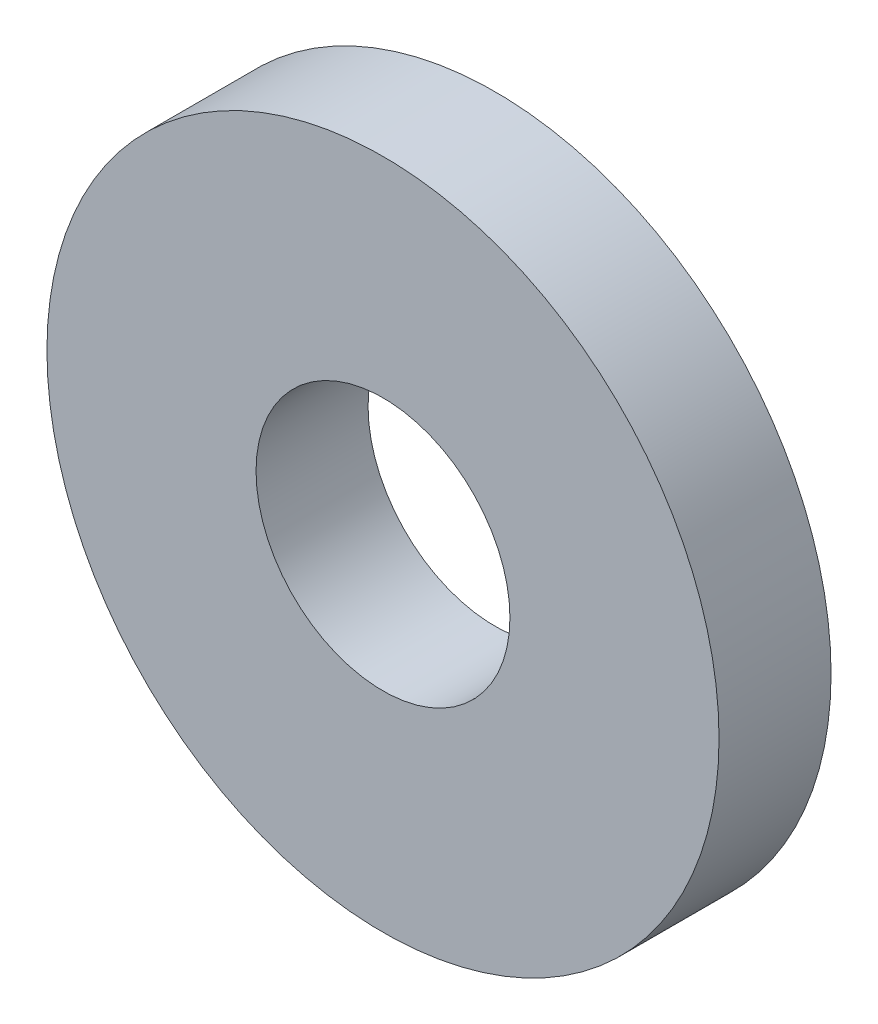
from build123d import *

# Parameters (mm, degrees)
SKIZZE1_R                       = 45
SKIZZE1_R_2                     = 17
AUFSATZ_LINEAR_AUSTRAGEN1_DEPTH = 15


with BuildPart() as part:
    # Skizze1 → Aufsatz-Linear austragen1 (new body)
    with BuildSketch(Plane.XY):
        Circle(SKIZZE1_R)
        Circle(SKIZZE1_R_2, mode=Mode.SUBTRACT)
    extrude(amount=-AUFSATZ_LINEAR_AUSTRAGEN1_DEPTH)


solid = part.part
